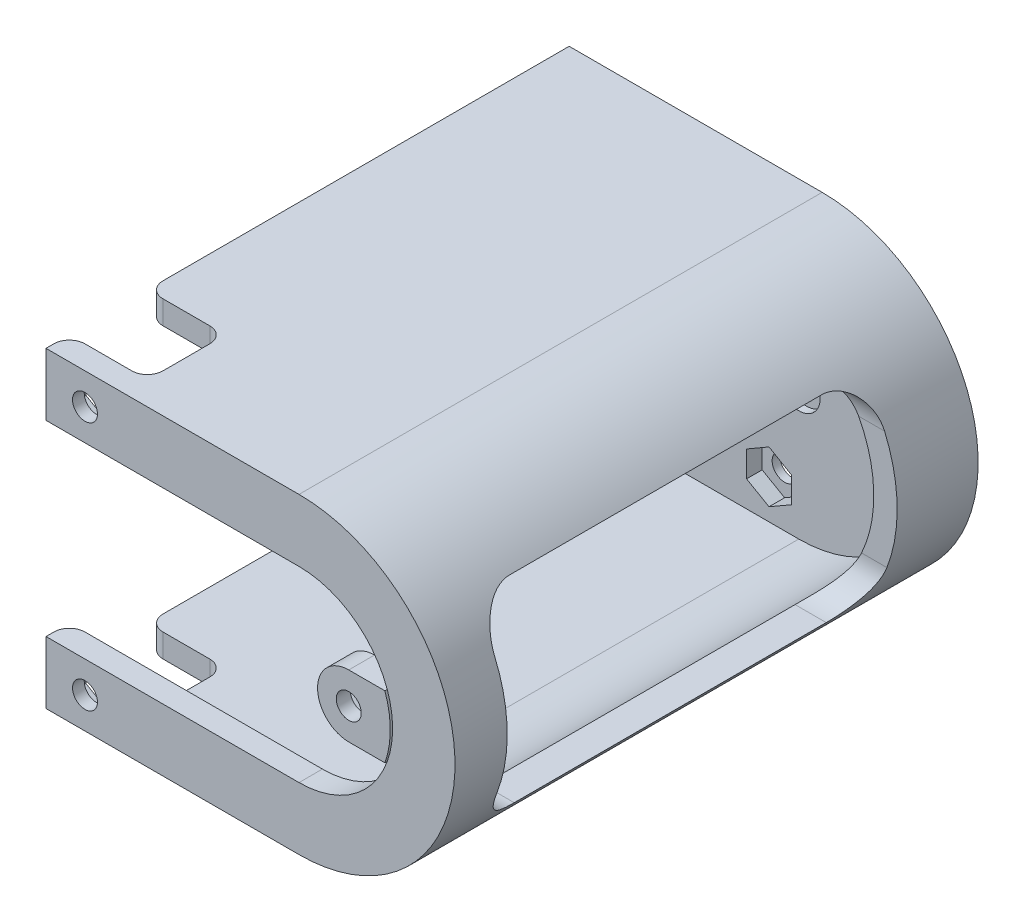
from build123d import *

# Parameters (mm, degrees)
BOSS_EXTRUDE1_DEPTH     = 3
BOSS_EXTRUDE2_DEPTH     = 64.08
BOSS_EXTRUDE3_START     = 0.3
BOSS_EXTRUDE3_DEPTH     = 3
CUT_EXTRUDE1_REACH      = 5
SKETCH4_R               = 1.65
CUT_EXTRUDE2_DEPTH      = 2
CUT_EXTRUDE3_REACH      = 5
SKETCH7_R               = 1.6
SKETCH10_W              = 10
SKETCH10_H              = 10
CUT_EXTRUDE4_DEPTH      = 38
CUT_EXTRUDE4_DEPTH_BACK = 4
CUT_EXTRUDE6_DEPTH      = 1.5
CUT_EXTRUDE7_REACH      = 5
SKETCH12_R              = 1.6
CUT_EXTRUDE8_REACH      = 87.591
BOSS_EXTRUDE4_DEPTH     = 3.3
CUT_EXTRUDE9_REACH      = 5.3
SKETCH15_R              = 1.6
CUT_EXTRUDE10_DEPTH     = 1.5
SKETCH17_R              = 8
CUT_EXTRUDE11_DEPTH     = 1
SKETCH18_R              = 2.75
CUT_EXTRUDE13_DEPTH     = 1
FILLET1_R               = 2
FILLET2_R               = 5


with BuildPart() as part:
    # Sketch1 → Boss-Extrude1 (new body)
    with BuildSketch(Plane.XY):
        with BuildLine():
            Line((-85.590530374, -20.367507575), (-53.15, -20.367507575))
            ThreePointArc((-53.15, -20.367507575), (-33.15, -0.367507575), (-53.15, 19.632492425))
            Line((-53.15, 19.632492425), (-85.590530374, 19.632492425))
            Line((-85.590530374, 19.632492425), (-85.590530374, -20.367507575))
        make_face()
    extrude(amount=BOSS_EXTRUDE1_DEPTH)

    # Sketch2 → Boss-Extrude2 (add)
    with BuildSketch(Plane.XY.offset(3)):
        with BuildLine():
            Line((-85.590530374, -20.367507575), (-53.15, -20.367507575))
            ThreePointArc((-53.15, -20.367507575), (-33.15, -0.367507575), (-53.15, 19.632492425))
            Line((-53.15, 19.632492425), (-85.590530374, 19.632492425))
            Line((-85.590530374, 19.632492425), (-85.590530374, 16.632492425))
            Line((-85.590530374, 16.632492425), (-53.15, 16.632492425))
            ThreePointArc((-53.15, 16.632492425), (-36.15, -0.367507575), (-53.15, -17.367507575))
            Line((-53.15, -17.367507575), (-85.590530374, -17.367507575))
            Line((-85.590530374, -17.367507575), (-85.590530374, -20.367507575))
        make_face()
    extrude(amount=BOSS_EXTRUDE2_DEPTH)

    # Sketch3 → Boss-Extrude3 (add)
    with BuildSketch(Plane(origin=(0, 0, 67.38), x_dir=(-1, 0, 0), z_dir=(0, 0, -1)).offset(BOSS_EXTRUDE3_START)):
        with BuildLine():
            Line((85.590530374, 19.632492425), (85.590530374, 11.632492425))
            Line((85.590530374, 11.632492425), (77.590530374, 11.632492425))
            Line((77.590530374, 11.632492425), (53.15, 11.632492425))
            ThreePointArc((53.15, 11.632492425), (41.15, -0.367507575), (53.15, -12.367507575))
            Line((53.15, -12.367507575), (77.590530374, -12.367507575))
            Line((77.590530374, -12.367507575), (85.590530374, -12.367507575))
            Line((85.590530374, -12.367507575), (85.590530374, -20.367507575))
            Line((85.590530374, -20.367507575), (53.15, -20.367507575))
            ThreePointArc((53.15, -20.367507575), (33.15, -0.367507575), (53.15, 19.632492425))
            Line((53.15, 19.632492425), (85.590530374, 19.632492425))
        make_face()
    extrude(amount=BOSS_EXTRUDE3_DEPTH)

    # Sketch4 → Cut-Extrude1 (cut, up to next)
    with BuildSketch(Plane.XY.offset(3), mode=Mode.PRIVATE) as cut_extrude1_sk1:
        with Locations((-77.35, -0.367507575)):
            Circle(SKETCH4_R)
    cut_extrude1_tool1 = extrude(cut_extrude1_sk1.sketch, amount=-CUT_EXTRUDE1_REACH, mode=Mode.PRIVATE) & part.part
    add(cut_extrude1_tool1.solids().sort_by_distance((-77.35, -0.367508, 3))[0], mode=Mode.SUBTRACT)
    # Sketch4 → Cut-Extrude1 (cut, up to next)
    with BuildSketch(Plane.XY.offset(3), mode=Mode.PRIVATE) as cut_extrude1_sk2:
        with Locations((-53.15, -0.367507575)):
            Circle(SKETCH4_R)
    cut_extrude1_tool2 = extrude(cut_extrude1_sk2.sketch, amount=-CUT_EXTRUDE1_REACH, mode=Mode.PRIVATE) & part.part
    add(cut_extrude1_tool2.solids().sort_by_distance((-53.15, -0.367508, 3))[0], mode=Mode.SUBTRACT)

    # Sketch6 → Cut-Extrude2 (cut)
    with BuildSketch(Plane.XY.offset(3)):
        Polygon((-77.715530374, -9.047743527), (-80.590530374, -10.707625551), (-80.590530374, -14.027389599), (-77.715530374, -15.687271623), (-74.840530374, -14.027389599), (-74.840530374, -10.707625551), align=None)
        Polygon((-56.965530374, -9.047743527), (-59.840530374, -10.707625551), (-59.840530374, -14.027389599), (-56.965530374, -15.687271623), (-54.090530374, -14.027389599), (-54.090530374, -10.707625551), align=None)
        Polygon((-77.715530374, 14.952256473), (-80.590530374, 13.292374449), (-80.590530374, 9.972610401), (-77.715530374, 8.312728377), (-74.840530374, 9.972610401), (-74.840530374, 13.292374449), align=None)
        Polygon((-56.965530374, 14.952256473), (-59.840530374, 13.292374449), (-59.840530374, 9.972610401), (-56.965530374, 8.312728377), (-54.090530374, 9.972610401), (-54.090530374, 13.292374449), align=None)
    extrude(amount=-CUT_EXTRUDE2_DEPTH, mode=Mode.SUBTRACT)

    # Sketch7 → Cut-Extrude3 (cut, up to next)
    with BuildSketch(Plane.XY.offset(3), mode=Mode.PRIVATE) as cut_extrude3_sk1:
        with Locations((-77.715530374, -12.367507575)):
            Circle(SKETCH7_R)
    cut_extrude3_tool1 = extrude(cut_extrude3_sk1.sketch, amount=-CUT_EXTRUDE3_REACH, mode=Mode.PRIVATE) & part.part
    add(cut_extrude3_tool1.solids().sort_by_distance((-77.71553, -12.367508, 3))[0], mode=Mode.SUBTRACT)
    # Sketch7 → Cut-Extrude3 (cut, up to next)
    with BuildSketch(Plane.XY.offset(3), mode=Mode.PRIVATE) as cut_extrude3_sk2:
        with Locations((-77.715530374, 11.632492425)):
            Circle(SKETCH7_R)
    cut_extrude3_tool2 = extrude(cut_extrude3_sk2.sketch, amount=-CUT_EXTRUDE3_REACH, mode=Mode.PRIVATE) & part.part
    add(cut_extrude3_tool2.solids().sort_by_distance((-77.71553, 11.632492, 3))[0], mode=Mode.SUBTRACT)
    # Sketch7 → Cut-Extrude3 (cut, up to next)
    with BuildSketch(Plane.XY.offset(3), mode=Mode.PRIVATE) as cut_extrude3_sk3:
        with Locations((-56.965530374, 11.632492425)):
            Circle(SKETCH7_R)
    cut_extrude3_tool3 = extrude(cut_extrude3_sk3.sketch, amount=-CUT_EXTRUDE3_REACH, mode=Mode.PRIVATE) & part.part
    add(cut_extrude3_tool3.solids().sort_by_distance((-56.96553, 11.632492, 3))[0], mode=Mode.SUBTRACT)
    # Sketch7 → Cut-Extrude3 (cut, up to next)
    with BuildSketch(Plane.XY.offset(3), mode=Mode.PRIVATE) as cut_extrude3_sk4:
        with Locations((-56.965530374, -12.367507575)):
            Circle(SKETCH7_R)
    cut_extrude3_tool4 = extrude(cut_extrude3_sk4.sketch, amount=-CUT_EXTRUDE3_REACH, mode=Mode.PRIVATE) & part.part
    add(cut_extrude3_tool4.solids().sort_by_distance((-56.96553, -12.367508, 3))[0], mode=Mode.SUBTRACT)

    # Sketch10 → Cut-Extrude4 (cut, two sides)
    with BuildSketch(Plane(origin=(0, -17.367507575, 0), x_dir=(1, 0, 0), z_dir=(0, 1, 0))) as cut_extrude4_sk:
        with Locations((-80.590530374, -59.08)):
            Rectangle(SKETCH10_W, SKETCH10_H)
    extrude(amount=CUT_EXTRUDE4_DEPTH, mode=Mode.SUBTRACT)
    extrude(cut_extrude4_sk.sketch, amount=-CUT_EXTRUDE4_DEPTH_BACK, mode=Mode.SUBTRACT)

    # Sketch11 → Cut-Extrude6 (cut)
    with BuildSketch(Plane(origin=(0, 0, 64.08), x_dir=(-1, 0, 0), z_dir=(0, 0, -1))):
        Polygon((80.590530374, 12.312728377), (83.465530374, 13.972610401), (83.465530374, 17.292374449), (80.590530374, 18.952256473), (77.715530374, 17.292374449), (77.715530374, 13.972610401), align=None)
        Polygon((80.595461682, -19.68726796), (83.467992856, -18.02311713), (83.463061548, -14.703356745), (80.585599066, -13.04774719), (77.713067892, -14.71189802), (77.7179992, -18.031658405), align=None)
    extrude(amount=-CUT_EXTRUDE6_DEPTH, mode=Mode.SUBTRACT)

    # Sketch12 → Cut-Extrude7 (cut, up to next)
    with BuildSketch(Plane(origin=(0, 0, 64.08), x_dir=(-1, 0, 0), z_dir=(0, 0, -1)), mode=Mode.PRIVATE) as cut_extrude7_sk1:
        with Locations((80.590530374, 15.632492425)):
            Circle(SKETCH12_R)
    cut_extrude7_tool1 = extrude(cut_extrude7_sk1.sketch, amount=-CUT_EXTRUDE7_REACH, mode=Mode.PRIVATE) & part.part
    add(cut_extrude7_tool1.solids().sort_by_distance((-80.59053, 15.632492, 64.08))[0], mode=Mode.SUBTRACT)
    # Sketch12 → Cut-Extrude7 (cut, up to next)
    with BuildSketch(Plane(origin=(0, 0, 64.08), x_dir=(-1, 0, 0), z_dir=(0, 0, -1)), mode=Mode.PRIVATE) as cut_extrude7_sk2:
        with Locations((80.590530374, -16.363236937)):
            Circle(SKETCH12_R)
    cut_extrude7_tool2 = extrude(cut_extrude7_sk2.sketch, amount=-CUT_EXTRUDE7_REACH, mode=Mode.PRIVATE) & part.part
    add(cut_extrude7_tool2.solids().sort_by_distance((-80.59053, -16.363237, 64.08))[0], mode=Mode.SUBTRACT)

    # Sketch13 → Cut-Extrude8 (cut, up to next)
    with BuildSketch(Plane(origin=(0, 0, 0), x_dir=(0, 0, -1), z_dir=(1, 0, 0)), mode=Mode.PRIVATE) as cut_extrude8_sk1:
        Polygon((-60.382396062, 0), (-60.382396062, -12.5), (-10.382396062, -12.5), (-10.382396062, 12.5), (-60.382396062, 12.5), align=None)
    cut_extrude8_tool1 = extrude(cut_extrude8_sk1.sketch, amount=-CUT_EXTRUDE8_REACH, mode=Mode.PRIVATE) & part.part
    add(cut_extrude8_tool1.solids().sort_by_distance((0, 0, 35.382396))[0], mode=Mode.SUBTRACT)

    # Sketch14 → Boss-Extrude4 (add)
    with BuildSketch(Plane(origin=(0, 0, 67.38), x_dir=(-1, 0, 0), z_dir=(0, 0, -1))):
        with BuildLine():
            Line((46.470700294, 3.632492425), (41.836291501, 3.632492425))
            ThreePointArc((41.836291501, 3.632492425), (41.149999808, -0.367507575), (41.836291501, -4.367507575))
            Line((41.836291501, -4.367507575), (46.470700294, -4.367507575))
            ThreePointArc((46.470700294, -4.367507575), (50.470700294, -0.367507575), (46.470700294, 3.632492425))
        make_face()
    extrude(amount=BOSS_EXTRUDE4_DEPTH)

    # Sketch15 → Cut-Extrude9 (cut, up to next)
    with BuildSketch(Plane(origin=(0, 0, 64.08), x_dir=(-1, 0, 0), z_dir=(0, 0, -1)), mode=Mode.PRIVATE) as cut_extrude9_sk1:
        with Locations((46.470700294, -0.367507575)):
            Circle(SKETCH15_R)
    cut_extrude9_tool1 = extrude(cut_extrude9_sk1.sketch, amount=-CUT_EXTRUDE9_REACH, mode=Mode.PRIVATE) & part.part
    add(cut_extrude9_tool1.solids().sort_by_distance((-46.4707, -0.367508, 64.08))[0], mode=Mode.SUBTRACT)

    # Sketch16 → Cut-Extrude10 (cut)
    with BuildSketch(Plane(origin=(0, 0, 64.08), x_dir=(-1, 0, 0), z_dir=(0, 0, -1))):
        Polygon((46.601103516, -3.684709458), (49.408683005, -1.913176014), (49.278279783, 1.40402587), (46.340297072, 2.949694308), (43.532717583, 1.178160864), (43.663120805, -2.139041019), align=None)
    extrude(amount=-CUT_EXTRUDE10_DEPTH, mode=Mode.SUBTRACT)

    # Sketch17 → Cut-Extrude11 (cut)
    with BuildSketch(Plane.XY.offset(3)):
        with Locations((-349.65, -0.367507575)):
            Circle(SKETCH17_R)
    extrude(amount=-CUT_EXTRUDE11_DEPTH, mode=Mode.SUBTRACT)

    # Sketch18 → Cut-Extrude13 (cut)
    with BuildSketch(Plane.XY.offset(3)):
        with Locations((-53.15, -0.367507575)):
            Circle(SKETCH18_R)
        with Locations((-77.35, -0.367507575)):
            Circle(SKETCH18_R)
    extrude(amount=-CUT_EXTRUDE13_DEPTH, mode=Mode.SUBTRACT)

    # Fillet1
    fillet1_edges = [part.edges().sort_by_distance(p)[0] for p in [
        (-85.590530374, 18.132492425, 54.08),
        (-85.590530374, -18.867507575, 54.08),
        (-75.590530374, 18.132492425, 54.08),
        (-75.590530374, -18.867507575, 54.08),
        (-75.590530374, 18.132492425, 64.08),
        (-75.590530374, -18.867507575, 64.08),
        (-85.590530374, 15.632492425, 64.08),
        (-85.590530374, -16.367507575, 64.08),
    ]]
    fillet(fillet1_edges, radius=FILLET1_R)

    # Fillet2
    fillet2_edges = [part.edges().sort_by_distance(p)[0] for p in [
        (-39.939600546, 12.5, 60.382396062),
        (-39.939600546, 12.5, 10.382396062),
        (-39.246070498, -12.5, 10.382396062),
        (-39.246070498, -12.5, 60.382396062),
    ]]
    fillet(fillet2_edges, radius=FILLET2_R)


solid = part.part
